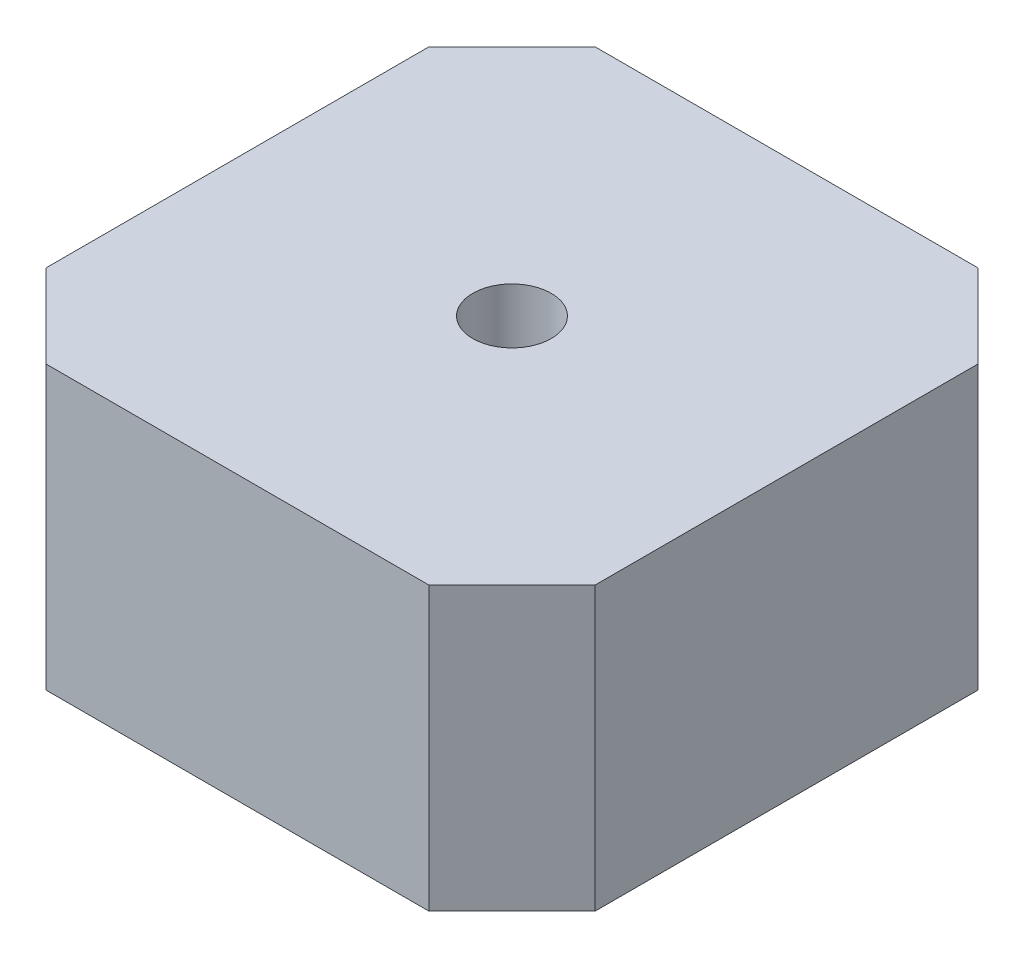
from build123d import *

# Parameters (mm, degrees)
CROQUIS1_W              = 35
CROQUIS1_H              = 35
SALIENTE_EXTRUIR1_DEPTH = 18
CROQUIS2_OUTSIDE_W      = 47.534
CROQUIS2_OUTSIDE_H      = 47.534
CORTAR_EXTRUIR2_DEPTH   = 18
CROQUIS3_R              = 2.5
CORTAR_EXTRUIR3_DEPTH   = 19


with BuildPart() as part:
    # Croquis1 → Saliente-Extruir1 (new body)
    with BuildSketch(Plane(origin=(0, 0, 0), x_dir=(1, 0, 0), z_dir=(0, 1, 0))):
        with Locations((17.5, 17.5)):
            Rectangle(CROQUIS1_W, CROQUIS1_H)
    extrude(amount=SALIENTE_EXTRUIR1_DEPTH)

    # Croquis2 outside → Cortar-Extruir2 (cut)
    with BuildSketch(Plane(origin=(0, 18, 0), x_dir=(1, 0, 0), z_dir=(0, 1, 0))):
        with Locations((17.5, 17.5)):
            Rectangle(CROQUIS2_OUTSIDE_W, CROQUIS2_OUTSIDE_H)
        Polygon((5.30151519, 35), (0, 29.69848481), (0, 5.30151519), (5.30151519, 0), (29.69848481, 0), (35, 5.30151519), (35, 29.69848481), (29.69848481, 35), align=None, mode=Mode.SUBTRACT)
    extrude(amount=-CORTAR_EXTRUIR2_DEPTH, mode=Mode.SUBTRACT)

    # Croquis3 → Cortar-Extruir3 (cut, through all)
    with BuildSketch(Plane(origin=(0, 18, 0), x_dir=(1, 0, 0), z_dir=(0, 1, 0))):
        with Locations((17.5, 17.5)):
            Circle(CROQUIS3_R)
    extrude(amount=-CORTAR_EXTRUIR3_DEPTH, mode=Mode.SUBTRACT)


solid = part.part
